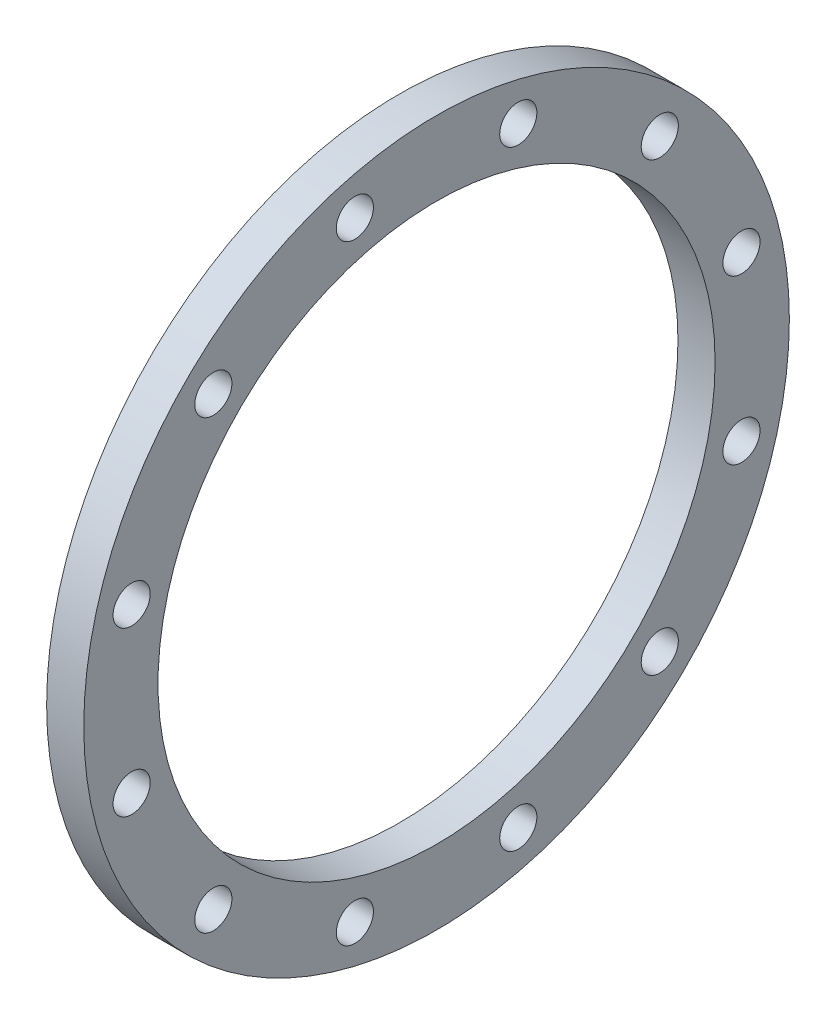
from build123d import *

# Parameters (mm, degrees)
SKETCH6_R                = 241.3
SKETCH6_R_2              = 190.5
BOSS_EXTRUDE1_DEPTH      = 12.7
F_7_8_1_DIAMETER_HOLE1_D = 25.4
CIRPATTERN1_COUNT        = 12


with BuildPart() as part:
    # Sketch6 → Boss-Extrude1 (new, symmetric)
    with BuildSketch(Plane(origin=(0, 0, 0), x_dir=(0, 0, -1), z_dir=(1, 0, 0))):
        with Locations((0, 316.3)):
            Circle(SKETCH6_R)
        with Locations((0, 316.3)):
            Circle(SKETCH6_R_2, mode=Mode.SUBTRACT)
    extrude(amount=BOSS_EXTRUDE1_DEPTH, both=True)

    # 7_8 _1_ Diameter Hole1 (through all)
    with Locations(Plane(origin=(12.7, 0, 0), x_dir=(0, 0, -1), z_dir=(1, 0, 0))):
        with Locations((208.543385896, 260.420968162)):
            f_7_8_1_diameter_hole1 = Hole(F_7_8_1_DIAMETER_HOLE1_D / 2)

    # CirPattern1: 7_8 _1_ Diameter Hole1 ×12 about axis
    cirpattern1_axis = Axis((12.7, 316.3, 0), (-1, 0, 0))
    for i in range(1, CIRPATTERN1_COUNT):
        add(f_7_8_1_diameter_hole1.rotate(cirpattern1_axis, i * 360 / CIRPATTERN1_COUNT), mode=Mode.SUBTRACT)


solid = part.part
